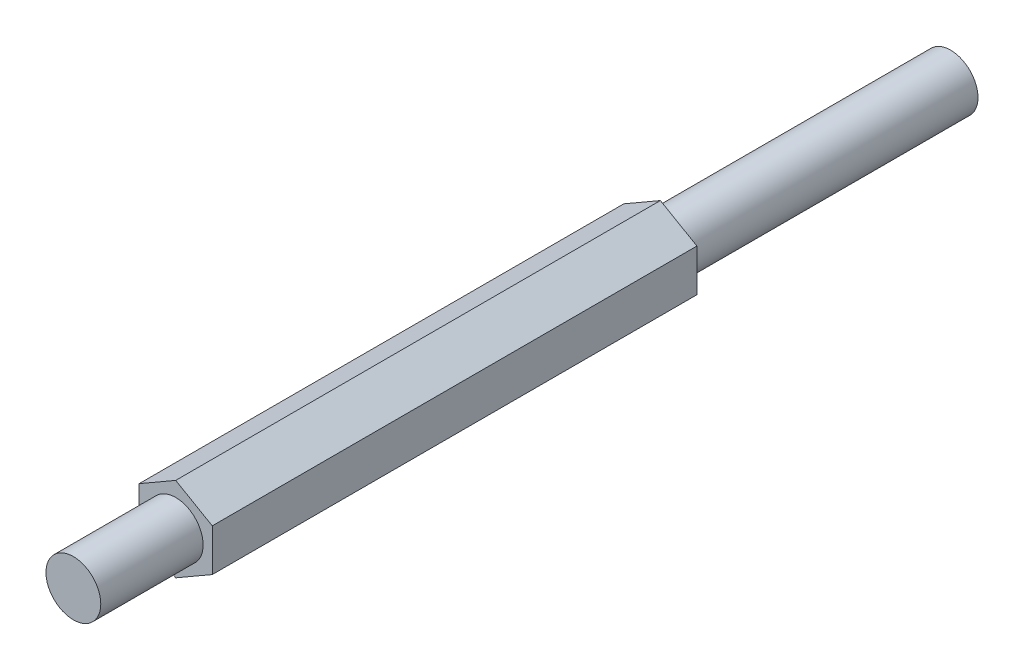
from build123d import *

# Parameters (mm, degrees)
BOSS_EXTRUDE1_DEPTH      = 116.84
BOSS_EXTRUDE1_DEPTH_BACK = 51.562
SKETCH1_3_R              = 9.525
BOSS_EXTRUDE2_DEPTH      = 152.4


with BuildPart() as part:
    # Sketch1 → Boss-Extrude1 (new, two sides: drawn at the far end of the back side and taken through both)
    with BuildSketch(Plane.XY.offset(-BOSS_EXTRUDE1_DEPTH_BACK)):
        Polygon((-12.7, -7.332348419), (0, -14.664696837), (12.7, -7.332348419), (12.7, 7.332348419), (0, 14.664696837), (-12.7, 7.332348419), align=None)
    extrude(amount=BOSS_EXTRUDE1_DEPTH + BOSS_EXTRUDE1_DEPTH_BACK)

    # Sketch1_3 → Boss-Extrude2 (add, symmetric)
    with BuildSketch(Plane.XY):
        Circle(SKETCH1_3_R)
    extrude(amount=BOSS_EXTRUDE2_DEPTH, both=True)


solid = part.part
